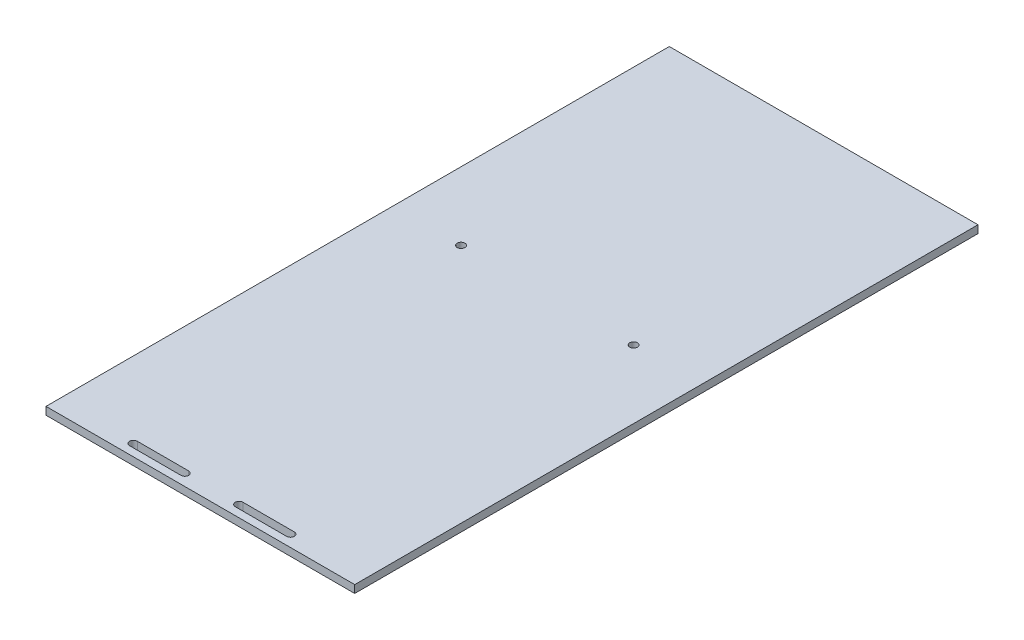
from build123d import *

# Parameters (mm, degrees)
SKETCH_1_W          = 120.112060779
SKETCH_1_H          = 242.505963566
EXTRUDE_1_DEPTH     = 3
SKETCH_3_R          = 1.5
CUT_EXTRUDE_5_DEPTH = 3


with BuildPart() as part:
    # 草图1 → 凸台-拉伸1 (new body)
    with BuildSketch(Plane(origin=(0, 0, 0), x_dir=(1, 0, 0), z_dir=(0, 1, 0))):
        with Locations((60.05603039, -121.252981783)):
            Rectangle(SKETCH_1_W, SKETCH_1_H)
    extrude(amount=EXTRUDE_1_DEPTH)

    # 草图3 → 切除-拉伸5 (cut)
    with BuildSketch(Plane(origin=(0, 3, 0), x_dir=(1, 0, 0), z_dir=(0, 1, 0))):
        with Locations((26.5, -107.505963566)):
            Circle(SKETCH_3_R)
        with Locations((93.612060779, -107.505963566)):
            Circle(SKETCH_3_R)
        with BuildLine():
            Line((29.5, -236.5), (49.5, -236.5))
            ThreePointArc((49.5, -236.5), (51, -238), (49.5, -239.5))
            Line((49.5, -239.5), (29.5, -239.5))
            ThreePointArc((29.5, -239.5), (28, -238), (29.5, -236.5))
        make_face()
        with BuildLine():
            Line((70.612060779, -236.5), (90.612060779, -236.5))
            ThreePointArc((90.612060779, -236.5), (92.112060779, -238), (90.612060779, -239.5))
            Line((90.612060779, -239.5), (70.612060779, -239.5))
            ThreePointArc((70.612060779, -239.5), (69.112060779, -238), (70.612060779, -236.5))
        make_face()
    extrude(amount=-CUT_EXTRUDE_5_DEPTH, mode=Mode.SUBTRACT)


solid = part.part
